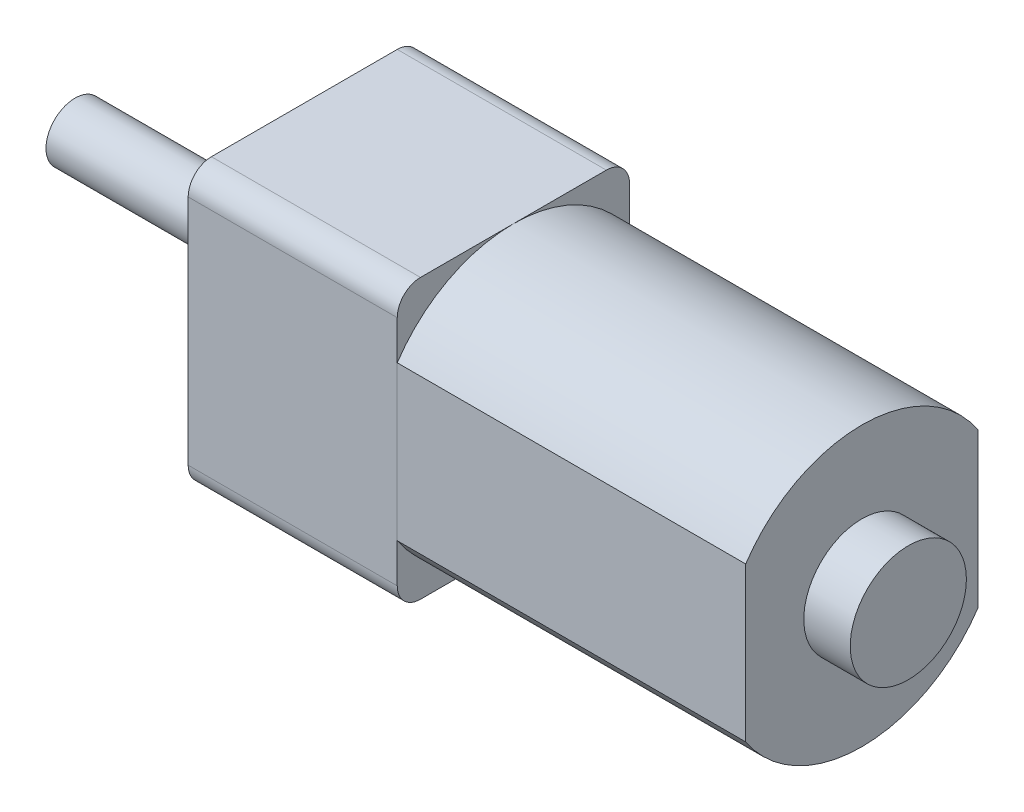
from build123d import *

# Parameters (mm, degrees)
EXTRUDE1_DEPTH = 15
SKETCH2_W      = 10
SKETCH2_H      = 12
SKETCH2_R      = 1.404547398
EXTRUDE2_DEPTH = 9
SKETCH3_R      = 2.5
EXTRUDE3_DEPTH = 2
SKETCH4_R      = 1.95
EXTRUDE4_DEPTH = 0.6
SKETCH5_R      = 1.25
EXTRUDE5_DEPTH = 9.27
FILLET1_R      = 1


with BuildPart() as part:
    # Sketch1 → Extrude1 (new body)
    with BuildSketch(Plane(origin=(0, 0, 0), x_dir=(0, 0, -1), z_dir=(1, 0, 0))):
        with BuildLine():
            Line((-5, 3.31662479), (-5, -3.31662479))
            ThreePointArc((-5, -3.31662479), (0, -6), (5, -3.31662479))
            Line((5, -3.31662479), (5, 3.31662479))
            ThreePointArc((5, 3.31662479), (0, 6), (-5, 3.31662479))
        make_face()
    extrude(amount=-EXTRUDE1_DEPTH)


with BuildPart() as body_2:
    # Sketch2 → Extrude2 (new body)
    with BuildSketch(Plane.ZY.offset(15)):
        Rectangle(SKETCH2_W, SKETCH2_H)
        Circle(SKETCH2_R, mode=Mode.SUBTRACT)
    extrude(amount=EXTRUDE2_DEPTH)

    # Fillet1
    fillet1_edges = [body_2.edges().sort_by_distance(p)[0] for p in [
        (-19.5, -6, 5),
        (-19.5, -6, -5),
        (-19.5, 6, -5),
        (-19.5, 6, 5),
    ]]
    fillet(fillet1_edges, radius=FILLET1_R)


with BuildPart() as body_3:
    # Sketch3 → Extrude3 (new body)
    with BuildSketch(Plane(origin=(0, 0, 0), x_dir=(0, 0, -1), z_dir=(1, 0, 0))):
        Circle(SKETCH3_R)
    extrude(amount=EXTRUDE3_DEPTH)


with BuildPart() as body_4:
    # Sketch4 → Extrude4 (new body)
    with BuildSketch(Plane.ZY.offset(24)):
        Circle(SKETCH4_R)
    extrude(amount=EXTRUDE4_DEPTH)

    # Sketch5 → Extrude5 (add)
    with BuildSketch(Plane.ZY.offset(24.6)):
        Circle(SKETCH5_R)
    extrude(amount=EXTRUDE5_DEPTH)


solid = Compound([part.part, body_2.part, body_3.part, body_4.part])
